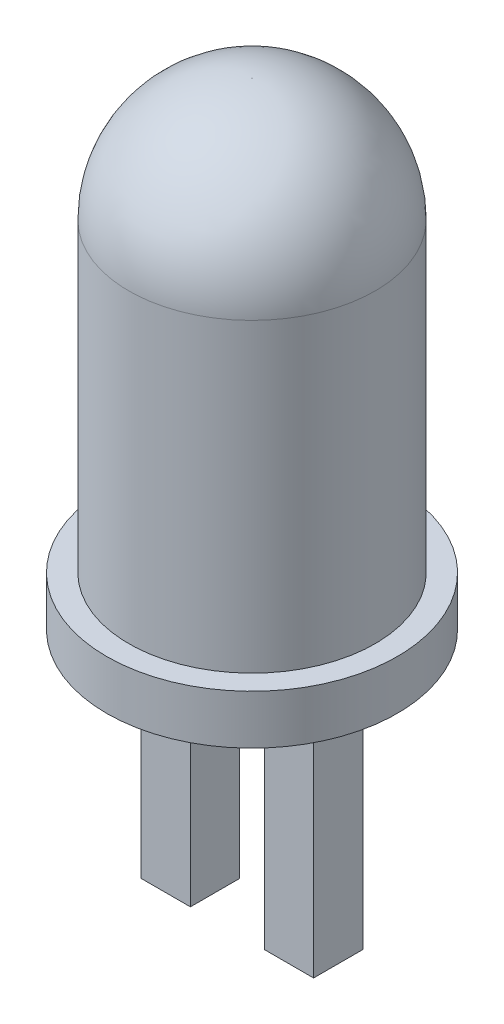
from build123d import *

# Parameters (mm, degrees)
SKETCH2_W           = 1
SKETCH2_H           = 1
BOSS_EXTRUDE1_DEPTH = 5


with BuildPart() as part:
    # Sketch1 → Revolve1 (revolve)
    with BuildSketch(Plane(origin=(0, 0, 0), x_dir=(0, 0, -1), z_dir=(1, 0, 0))):
        with BuildLine():
            Line((0, 0), (0, 9.69))
            Line((0, 9.69), (-0.01, 9.69))
            ThreePointArc((-0.01, 9.69), (-1.770695885, 8.960695885), (-2.5, 7.2))
            Line((-2.5, 7.2), (-2.5, 1))
            Line((-2.5, 1), (-2.95, 1))
            Line((-2.95, 1), (-2.95, 0))
            Line((-2.95, 0), (0, 0))
        make_face()
    revolve(axis=Axis((0, 0, 0), (0, 1, 0)))

    # Sketch2 → Boss-Extrude1 (add)
    with BuildSketch(Plane.XZ):
        with Locations((-1.25, 0)):
            Rectangle(SKETCH2_W, SKETCH2_H)
        with Locations((1.25, 0)):
            Rectangle(SKETCH2_W, SKETCH2_H)
    extrude(amount=BOSS_EXTRUDE1_DEPTH)


solid = part.part
